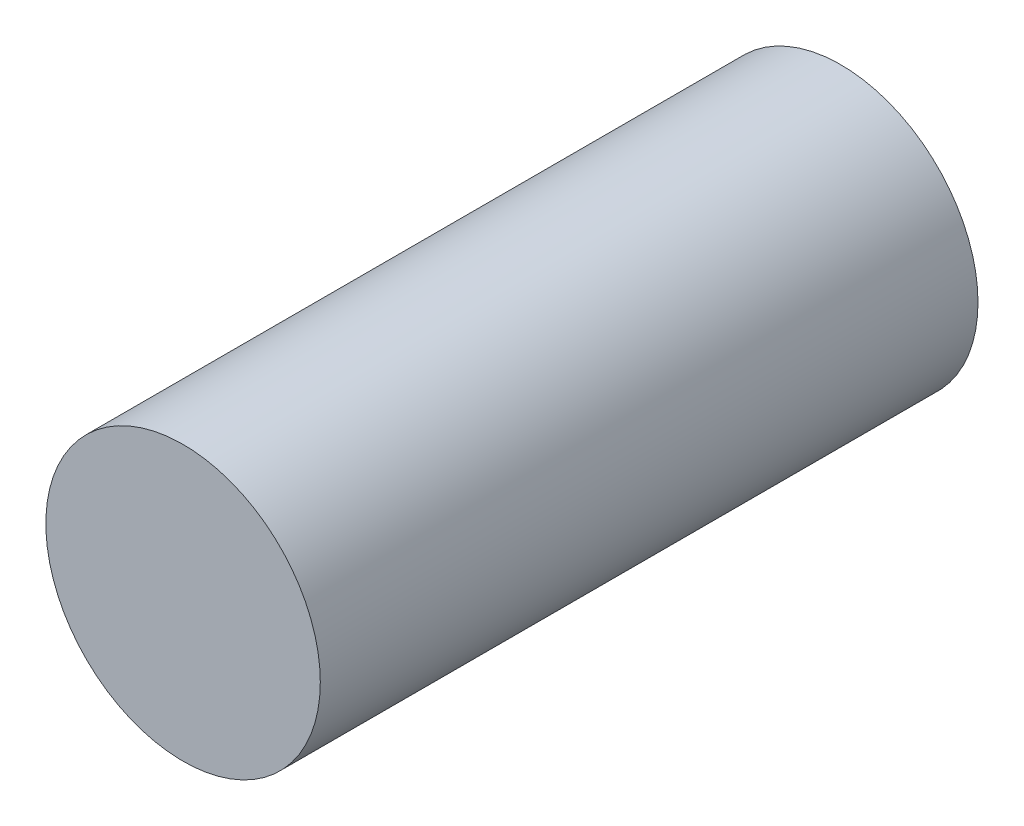
from build123d import *

# Parameters (mm, degrees)
SKETCH1_R           = 15.9
BOSS_EXTRUDE1_DEPTH = 76.2


with BuildPart() as part:
    # Sketch1 → Boss-Extrude1 (new body)
    with BuildSketch(Plane.XY):
        Circle(SKETCH1_R)
    extrude(amount=BOSS_EXTRUDE1_DEPTH)


solid = part.part
